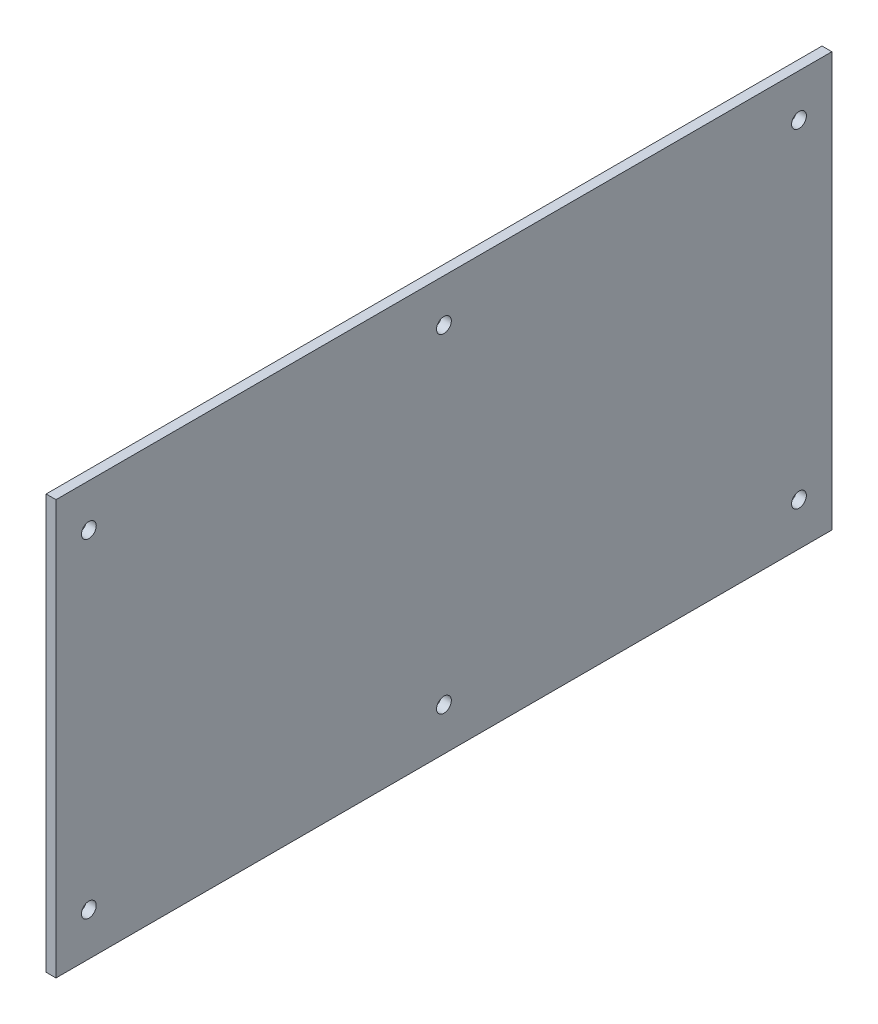
from build123d import *

# Parameters (mm, degrees)
SKETCH_1_W          = 236
SKETCH_1_H          = 126
EXTRUDE_1_DEPTH     = 3
SKETCH_3_R          = 2.25
CUT_EXTRUDE_1_DEPTH = 4


with BuildPart() as part:
    # Эскиз1 → Бобышка-Вытянуть1 (new body)
    with BuildSketch(Plane(origin=(20, 0, 0), x_dir=(0, 0, -1), z_dir=(1, 0, 0))):
        with Locations((-118, 60)):
            Rectangle(SKETCH_1_W, SKETCH_1_H)
    extrude(amount=EXTRUDE_1_DEPTH)

    # Эскиз3 → Вырез-Вытянуть1 (cut, through all)
    with BuildSketch(Plane(origin=(23, 0, 0), x_dir=(0, 0, -1), z_dir=(1, 0, 0))):
        with Locations((-10, 110)):
            Circle(SKETCH_3_R)
        with Locations((-10, 10)):
            Circle(SKETCH_3_R)
        with Locations((-226, 110)):
            Circle(SKETCH_3_R)
        with Locations((-226, 10)):
            Circle(SKETCH_3_R)
        with Locations((-118, 110)):
            Circle(SKETCH_3_R)
        with Locations((-118, 10)):
            Circle(SKETCH_3_R)
    extrude(amount=-CUT_EXTRUDE_1_DEPTH, mode=Mode.SUBTRACT)


solid = part.part
